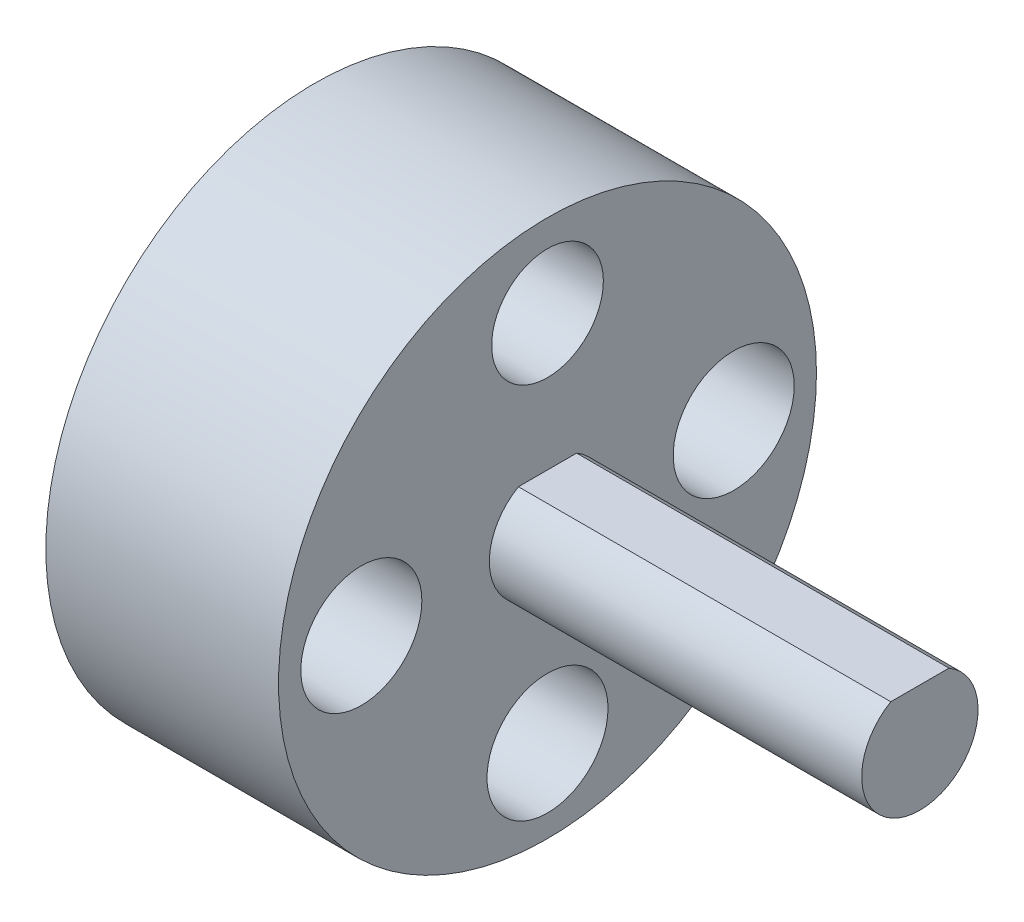
from build123d import *

# Parameters (mm, degrees)
SKETCH1_R           = 11.557
SKETCH1_R_2         = 2.6
SKETCH1_R_3         = 2.4
BOSS_EXTRUDE1_DEPTH = 10
BOSS_EXTRUDE2_DEPTH = 16


with BuildPart() as part:
    # Sketch1 → Boss-Extrude1 (new body)
    with BuildSketch(Plane(origin=(0, 0, 0), x_dir=(0, 0, -1), z_dir=(1, 0, 0))):
        Circle(SKETCH1_R)
        with Locations((8, 0)):
            Circle(SKETCH1_R_2, mode=Mode.SUBTRACT)
        with Locations((0, -8)):
            Circle(SKETCH1_R_2, mode=Mode.SUBTRACT)
        with Locations((-8, 0)):
            Circle(SKETCH1_R_2, mode=Mode.SUBTRACT)
        with Locations((0, 8)):
            Circle(SKETCH1_R_3, mode=Mode.SUBTRACT)
    extrude(amount=BOSS_EXTRUDE1_DEPTH)

    # Sketch2 → Boss-Extrude2 (add)
    with BuildSketch(Plane(origin=(10, 0, 0), x_dir=(0, 0, -1), z_dir=(1, 0, 0))):
        with BuildLine():
            Line((1.25, 2.165063509), (-1.25, 2.165063509))
            ThreePointArc((-1.25, 2.165063509), (-1.25, -2.165063509), (2.5, 0))
            ThreePointArc((2.5, 0), (2.165063509, 1.25), (1.25, 2.165063509))
        make_face()
    extrude(amount=BOSS_EXTRUDE2_DEPTH)


solid = part.part
